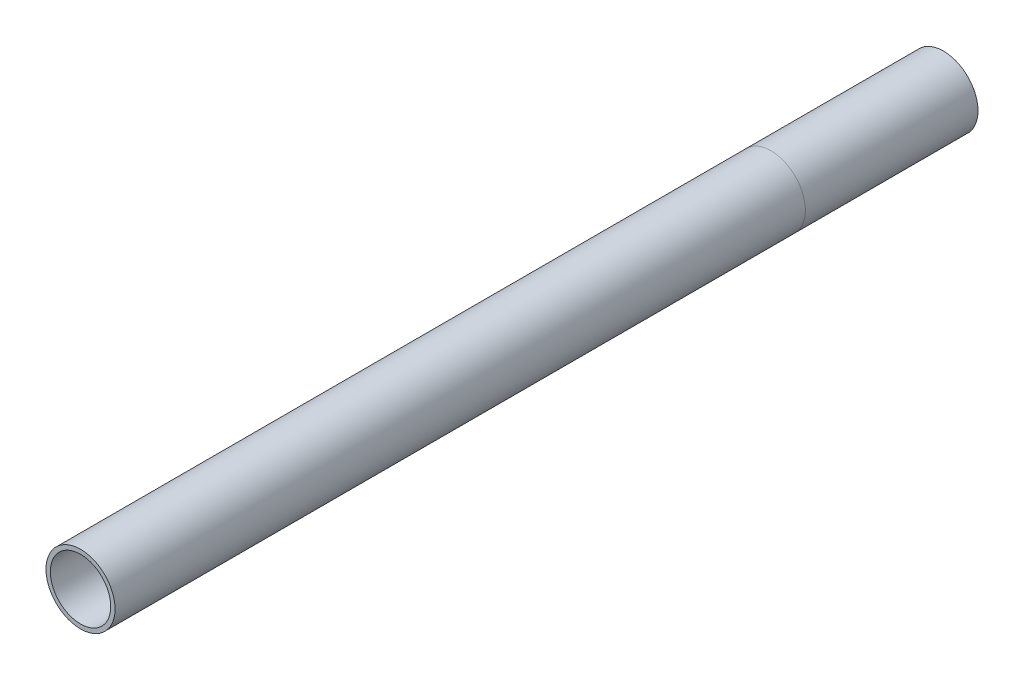
from build123d import *

# Parameters (mm, degrees)
SKETCH1_R           = 8
SKETCH1_R_2         = 7
BOSS_EXTRUDE1_DEPTH = 200


with BuildPart() as part:
    # Sketch1 → Boss-Extrude1 (new body)
    with BuildSketch(Plane.XY):
        Circle(SKETCH1_R)
        Circle(SKETCH1_R_2, mode=Mode.SUBTRACT)
    extrude(amount=BOSS_EXTRUDE1_DEPTH)


solid = part.part
